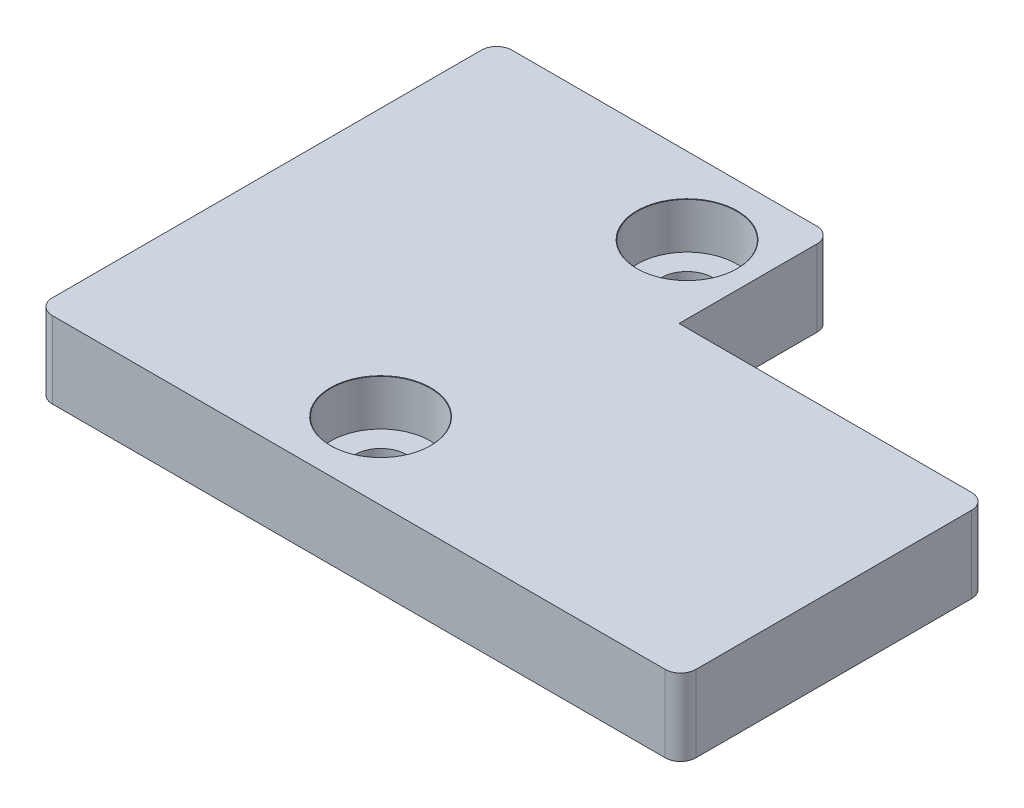
from build123d import *

# Parameters (mm, degrees)
SKETCH1_W                     = 42
SKETCH1_H                     = 20
BOSS_EXTRUDE1_DEPTH           = 5
SKETCH2_W                     = 21.9
SKETCH2_H                     = 10
BOSS_EXTRUDE2_DEPTH           = 5
CBORE_FOR_M3_SHCS1_AT_2_COUNT = 2
CBORE_FOR_M3_SHCS1_AT_2_PITCH = 20
FILLET1_R                     = 1


with BuildPart() as part:
    # Sketch1 → Boss-Extrude1 (new body)
    with BuildSketch(Plane(origin=(0, 0, 0), x_dir=(1, 0, 0), z_dir=(0, 1, 0))):
        Rectangle(SKETCH1_W, SKETCH1_H)
    extrude(amount=BOSS_EXTRUDE1_DEPTH)

    # Sketch2 → Boss-Extrude2 (add)
    with BuildSketch(Plane(origin=(0, 5, 0), x_dir=(1, 0, 0), z_dir=(0, 1, 0))):
        with Locations((-10.05, 15)):
            Rectangle(SKETCH2_W, SKETCH2_H)
    extrude(amount=-BOSS_EXTRUDE2_DEPTH)

    # Sketch7 → CBORE for M3 SHCS1 (revolve, cut)
    with BuildSketch(Plane(origin=(-3.575, 5, -15), x_dir=(0, 0, 1), z_dir=(1, 0, 0))):
        Polygon((0, 0), (0, 5), (1.7, 5), (1.7, 3), (3.25, 3), (3.25, 0.020977491), (3.275, 0), align=None)
    cbore_for_m3_shcs1 = revolve(axis=Axis((-3.575, 11.35, -15), (0, -1, 0)), mode=Mode.SUBTRACT)

    # CBORE for M3 SHCS1 at 2: CBORE for M3 SHCS1 ×2
    with Locations(*[(0, 0, i * CBORE_FOR_M3_SHCS1_AT_2_PITCH) for i in range(1, CBORE_FOR_M3_SHCS1_AT_2_COUNT)]):
        add(cbore_for_m3_shcs1, mode=Mode.SUBTRACT)

    # Fillet1
    fillet1_edges = [part.edges().sort_by_distance(p)[0] for p in [
        (-21, 2.5, -20),
        (0.9, 2.5, -20),
        (21, 2.5, -10),
        (21, 2.5, 10),
        (-21, 2.5, 10),
    ]]
    fillet(fillet1_edges, radius=FILLET1_R)


solid = part.part
